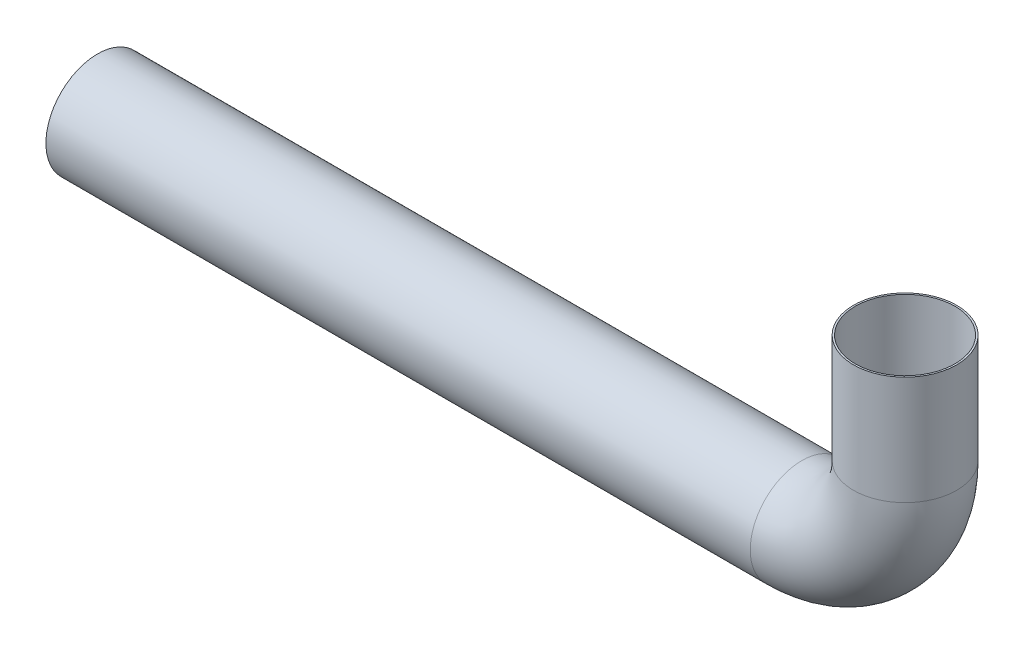
from build123d import *

# Parameters (mm, degrees)
SWEEP_THIN1_PROFILE_R   = 30
SWEEP_THIN1_PROFILE_R_2 = 29


with BuildPart() as part:
    # Sweep-Thin1: sweep along a curve in space
    with BuildLine() as sweep_thin1_path:
        Line((-30068.540907505, -16257.859563295, 40521.703196056), (-29659.188972505, -16257.859563295, 40521.703196056))
        ThreePointArc((-29599.188972505, -16197.859563295, 40521.703196056), (-29616.762565634, -16240.285970167, 40521.703196056), (-29659.188972505, -16257.859563295, 40521.703196056))
        Line((-29599.188972505, -16197.859563295, 40521.703196056), (-29599.188972505, -16134.686242211, 40521.703196056))
    # Sweep-Thin1 profile (on start of the path) → Sweep-Thin1 (sweep)
    with BuildSketch(Plane(origin=(-30068.540907505, -16257.859563295, 40521.703196056), x_dir=(0, 0, 1), z_dir=(1, 0, 0))):
        Circle(SWEEP_THIN1_PROFILE_R)
        Circle(SWEEP_THIN1_PROFILE_R_2, mode=Mode.SUBTRACT)
    sweep(path=sweep_thin1_path.line)


solid = part.part
